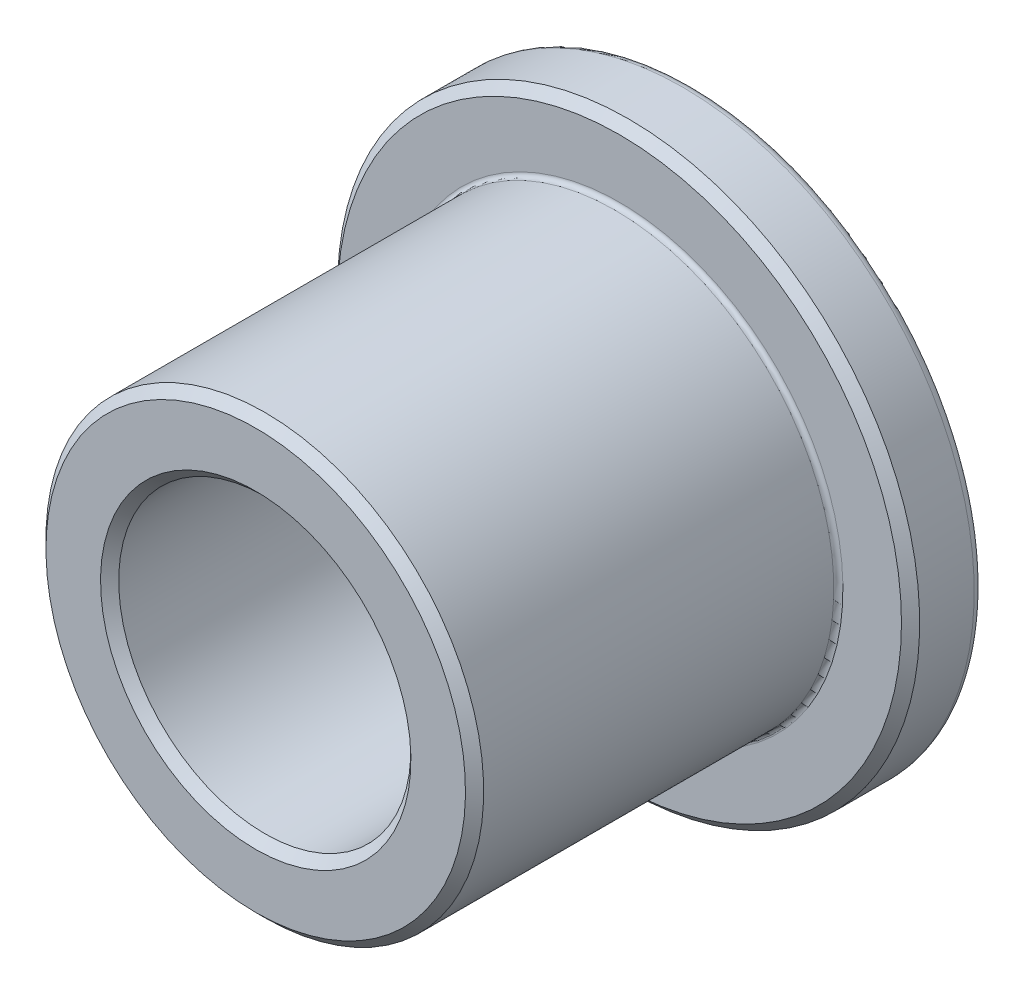
from build123d import *

# Parameters (mm, degrees)
CHAMFER1_SIZE = 0.1984375
FILLET1_R     = 0.1984375
FILLET2_R     = 0.09921875


with BuildPart() as part:
    # Sketch3 → Revolve1 (revolve)
    with BuildSketch(Plane(origin=(0, 0, 0), x_dir=(0, 0, -1), z_dir=(1, 0, 0))):
        Polygon((4.7625, 6.35), (3.175, 6.35), (3.175, 4.7752), (-4.7625, 4.7752), (-4.7625, 3.1877), (4.7625, 3.1877), align=None)
    revolve(axis=Axis((0, 0, -4.7625), (0, 0, 1)))

    # Chamfer1
    chamfer1_edges = [part.edges().sort_by_distance(p)[0] for p in [
        (0, -3.1877, 4.7625),
        (0, -4.7752, 4.7625),
        (0, -6.35, -3.175),
    ]]
    chamfer(chamfer1_edges, length=CHAMFER1_SIZE)

    # Fillet1
    fillet1_edges = [part.edges().sort_by_distance(p)[0] for p in [
        (0, -6.35, -4.7625),
    ]]
    fillet(fillet1_edges, radius=FILLET1_R)

    # Fillet2
    fillet2_edges = [part.edges().sort_by_distance(p)[0] for p in [
        (0, -4.7752, -3.175),
    ]]
    fillet(fillet2_edges, radius=FILLET2_R)


solid = part.part
